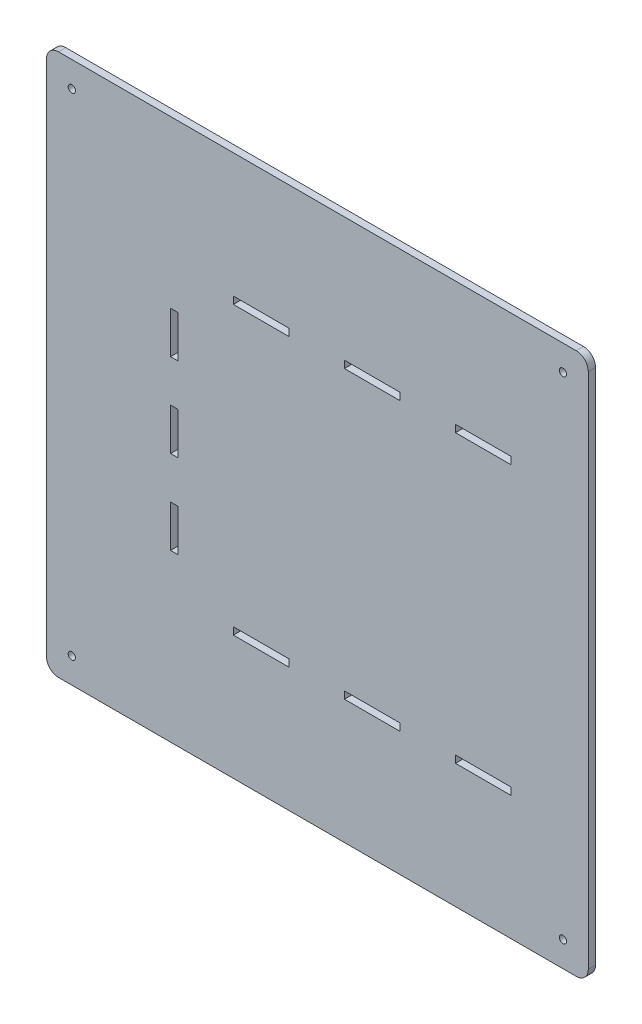
from build123d import *

# Parameters (mm, degrees)
SKETCH1_W           = 224.4
SKETCH1_H           = 224.4
SKETCH1_R           = 1.5
BOSS_EXTRUDE1_DEPTH = 3
FILLET2_R           = 5
SKETCH3_W           = 23
SKETCH3_H           = 3
SKETCH3_W_2         = 3
SKETCH3_H_2         = 17.37142857
CUT_EXTRUDE1_DEPTH  = 4


with BuildPart() as part:
    # Sketch1 → Boss-Extrude1 (new body)
    with BuildSketch(Plane.XY):
        with Locations((24.166161027, -19.850775129)):
            Rectangle(SKETCH1_W, SKETCH1_H)
        with Locations((125.866161027, -121.550775129)):
            Circle(SKETCH1_R, mode=Mode.SUBTRACT)
        with Locations((125.866161027, 81.849224871)):
            Circle(SKETCH1_R, mode=Mode.SUBTRACT)
        with Locations((-77.533838973, -121.550775129)):
            Circle(SKETCH1_R, mode=Mode.SUBTRACT)
        with Locations((-77.533838973, 81.849224871)):
            Circle(SKETCH1_R, mode=Mode.SUBTRACT)
    extrude(amount=BOSS_EXTRUDE1_DEPTH)

    # Fillet2
    fillet2_edges = [part.edges().sort_by_distance(p)[0] for p in [
        (-88.033838973, 92.349224871, 1.5),
        (136.366161027, 92.349224871, 1.5),
        (136.366161027, -132.050775129, 1.5),
        (-88.033838973, -132.050775129, 1.5),
    ]]
    fillet(fillet2_edges, radius=FILLET2_R)

    # Sketch3 → Cut-Extrude1 (cut, through all)
    with BuildSketch(Plane.XY.offset(3)):
        with Locations((92.866161027, 39.449224871)):
            Rectangle(SKETCH3_W, SKETCH3_H)
        with Locations((46.866161027, 39.449224871)):
            Rectangle(SKETCH3_W, SKETCH3_H)
        with Locations((0.866161027, 39.449224871)):
            Rectangle(SKETCH3_W, SKETCH3_H)
        with Locations((-35.133838973, 14.892082014)):
            Rectangle(SKETCH3_W_2, SKETCH3_H_2)
        with Locations((-35.133838973, -19.850775126)):
            Rectangle(SKETCH3_W_2, SKETCH3_H_2)
        with Locations((-35.133838973, -54.593632266)):
            Rectangle(SKETCH3_W_2, SKETCH3_H_2)
        with Locations((0.866161027, -79.150775129)):
            Rectangle(SKETCH3_W, SKETCH3_H)
        with Locations((46.866161027, -79.150775129)):
            Rectangle(SKETCH3_W, SKETCH3_H)
        with Locations((92.866161027, -79.150775129)):
            Rectangle(SKETCH3_W, SKETCH3_H)
    extrude(amount=-CUT_EXTRUDE1_DEPTH, mode=Mode.SUBTRACT)


solid = part.part
